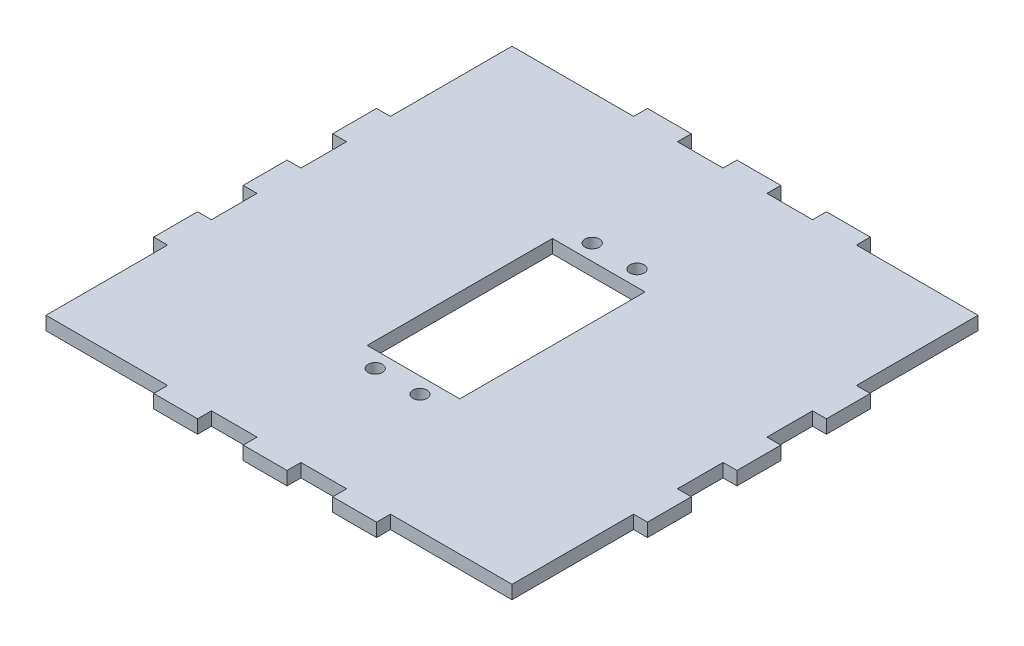
from build123d import *

# Parameters (mm, degrees)
SKETCH1_W           = 110.344434204
SKETCH1_H           = 110.344434204
SKETCH1_R           = 1.6
SKETCH1_W_2         = 20.7
SKETCH1_H_2         = 41.4
BOSS_EXTRUDE1_DEPTH = 3
SKETCH3_W           = 10.2
SKETCH3_H           = 3.2
SKETCH3_W_2         = 3.2
SKETCH3_H_2         = 10.2
CUT_EXTRUDE1_DEPTH  = 4


with BuildPart() as part:
    # Sketch1 → Boss-Extrude1 (new body)
    with BuildSketch(Plane(origin=(0, 0, 0), x_dir=(1, 0, 0), z_dir=(0, 1, 0))):
        with Locations((0, 11.670773756)):
            Rectangle(SKETCH1_W, SKETCH1_H)
        with Locations((-5, 34.6)):
            Circle(SKETCH1_R, mode=Mode.SUBTRACT)
        with Locations((5, 34.6)):
            Circle(SKETCH1_R, mode=Mode.SUBTRACT)
        with Locations((5, -13.9)):
            Circle(SKETCH1_R, mode=Mode.SUBTRACT)
        with Locations((-5, -13.9)):
            Circle(SKETCH1_R, mode=Mode.SUBTRACT)
        with Locations((0, 10.35)):
            Rectangle(SKETCH1_W_2, SKETCH1_H_2, mode=Mode.SUBTRACT)
    extrude(amount=BOSS_EXTRUDE1_DEPTH)

    # Sketch3 → Cut-Extrude1 (cut, through all)
    with BuildSketch(Plane(origin=(0, 0, 0), x_dir=(1, 0, 0), z_dir=(0, 1, 0))):
        with Locations((10, 65.342990858)):
            Rectangle(SKETCH3_W, SKETCH3_H)
        Polygon((24.9, 66.942990858), (55.272217102, 66.942990858), (55.272217102, 36.570773756), (52.072217102, 36.570773756), (52.072217102, 63.742990858), (24.9, 63.742990858), align=None)
        with Locations((53.672217102, 21.670773756)):
            Rectangle(SKETCH3_W_2, SKETCH3_H_2)
        Polygon((24.9, -40.401443346), (52.072217102, -40.401443346), (52.072217102, -13.229226244), (55.272217102, -13.229226244), (55.272217102, -43.601443346), (24.9, -43.601443346), align=None)
        with Locations((53.672217102, 1.670773756)):
            Rectangle(SKETCH3_W_2, SKETCH3_H_2)
        Polygon((-52.072217102, -13.229226244), (-55.272217102, -13.229226244), (-55.272217102, -43.601443346), (-24.9, -43.601443346), (-24.9, -40.401443346), (-52.072217102, -40.401443346), align=None)
        with Locations((-53.672217102, 21.670773756)):
            Rectangle(SKETCH3_W_2, SKETCH3_H_2)
        with Locations((-10, 65.342990858)):
            Rectangle(SKETCH3_W, SKETCH3_H)
        Polygon((-55.272217102, 36.570773756), (-52.072217102, 36.570773756), (-52.072217102, 63.742990858), (-24.9, 63.742990858), (-24.9, 66.942990858), (-55.272217102, 66.942990858), align=None)
        with Locations((-53.672217102, 1.670773756)):
            Rectangle(SKETCH3_W_2, SKETCH3_H_2)
        with Locations((-10, -42.001443346)):
            Rectangle(SKETCH3_W, SKETCH3_H)
        with Locations((10, -42.001443346)):
            Rectangle(SKETCH3_W, SKETCH3_H)
    extrude(amount=CUT_EXTRUDE1_DEPTH, mode=Mode.SUBTRACT)


solid = part.part
